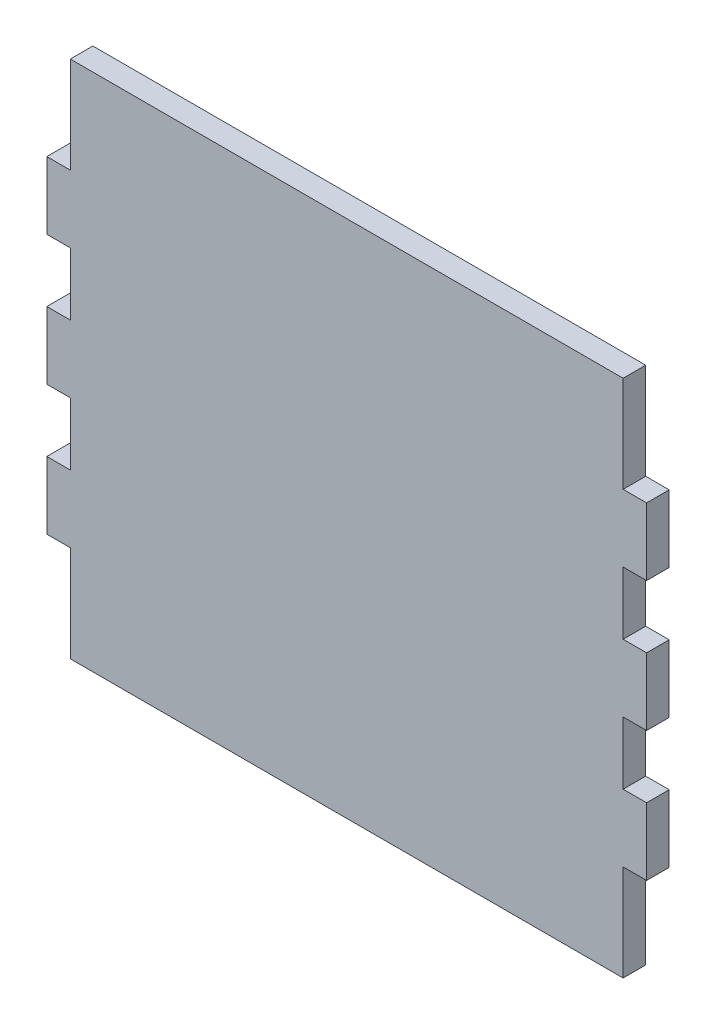
from build123d import *

# Parameters (mm, degrees)
BOSS_EXTRUDE1_DEPTH = 3.175


with BuildPart() as part:
    # Sketch1 → Boss-Extrude1 (new body, symmetric)
    with BuildSketch(Plane.XY):
        Polygon((77.724, 73.025), (-77.724, 73.025), (-77.724, 45.974), (-84.328, 45.974), (-84.328, 27.051), (-77.724, 27.051), (-77.724, 9.4615), (-84.328, 9.4615), (-84.328, -9.4615), (-77.724, -9.4615), (-77.724, -27.051), (-84.328, -27.051), (-84.328, -45.974), (-77.724, -45.974), (-77.724, -73.025), (77.724, -73.025), (77.724, -45.974), (84.328, -45.974), (84.328, -27.051), (77.724, -27.051), (77.724, -9.4615), (84.328, -9.4615), (84.328, 9.4615), (77.724, 9.4615), (77.724, 27.051), (84.328, 27.051), (84.328, 45.974), (77.724, 45.974), align=None)
    extrude(amount=BOSS_EXTRUDE1_DEPTH, both=True)


solid = part.part
